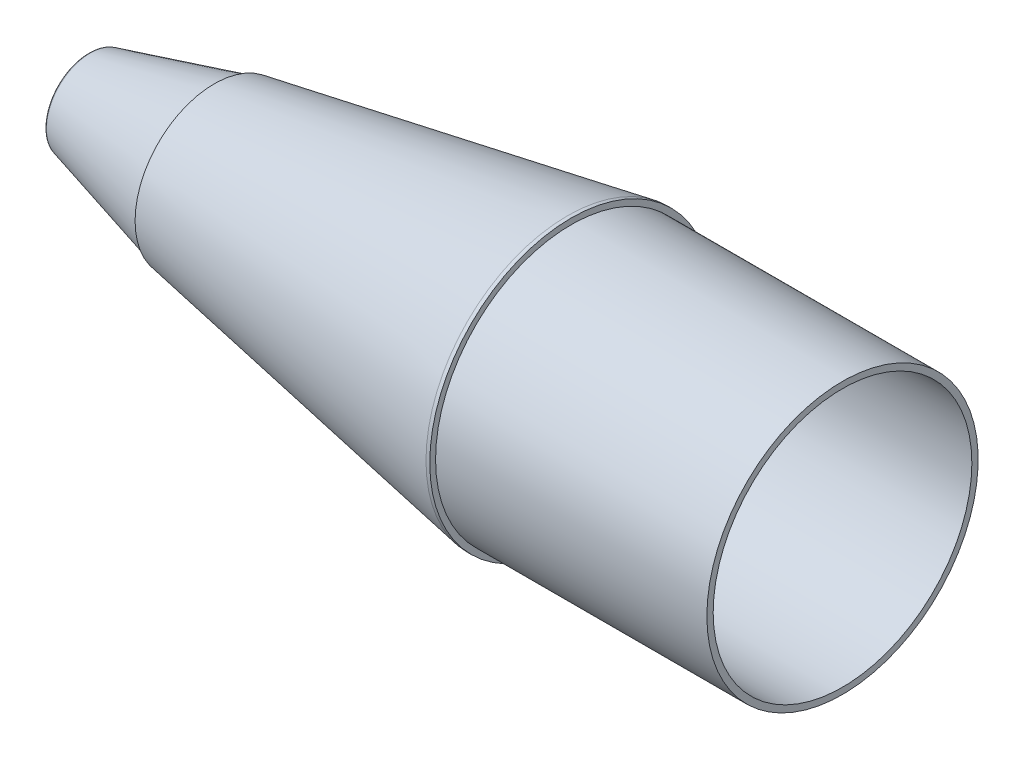
from build123d import *

# Parameters (mm, degrees)
FILLET1_R                    = 1.5494
F_0_257_DIAMETER_HOLE1_D     = 6.5278
F_0_257_DIAMETER_HOLE1_DEPTH = 13.913851026
F_0_257_DIAMETER_HOLE1_TIP   = 1.961148974
FILLET2_R                    = 0.508
SKETCH4_R                    = 7.366
CUT_EXTRUDE1_DEPTH           = 24.13
CUT_EXTRUDE1_TAPER           = -15
FILLET3_R                    = 0.254
CUT_EXTRUDE2_REACH           = 153.771
SKETCH5_R                    = 8.0264


with BuildPart() as part:
    # Sketch1 → Revolve1 (revolve)
    with BuildSketch(Plane.XY):
        Polygon((25.310022167, 15.9385), (96.398972647, 28.4734), (97.160972647, 28.4734), (97.160972647, 27.305), (151.770972647, 27.305), (151.770972647, 26.035), (91.346485275, 26.035), (27.94, 14.854725894), (27.94, 0), (0, 0), (0, 8.7376), (25.310022167, 15.5194), align=None)
    revolve(axis=Axis((0, 0, 0), (1, 0, 0)))

    # Fillet1
    fillet1_edges = [part.edges().sort_by_distance(p)[0] for p in [
        (27.94, -14.854725894, 0),
    ]]
    fillet(fillet1_edges, radius=FILLET1_R)

    # F (0.257) Diameter Hole1
    with Locations(Plane(origin=(27.94, 0, 0), x_dir=(0, 0, -1), z_dir=(1, 0, 0))):
        with Locations((0, 0)):
            Hole(F_0_257_DIAMETER_HOLE1_D / 2, depth=F_0_257_DIAMETER_HOLE1_DEPTH)
            with Locations((0, 0, -(F_0_257_DIAMETER_HOLE1_DEPTH + F_0_257_DIAMETER_HOLE1_TIP / 2))):  # 118° drill point
                Cone(0, F_0_257_DIAMETER_HOLE1_D / 2, F_0_257_DIAMETER_HOLE1_TIP, mode=Mode.SUBTRACT)

    # Fillet2
    fillet2_edges = [part.edges().sort_by_distance(p)[0] for p in [
        (0, -8.7376, 0),
    ]]
    fillet(fillet2_edges, radius=FILLET2_R)

    # Sketch4 → Cut-Extrude1 (cut)
    with BuildSketch(Plane.ZY):
        Circle(SKETCH4_R)
    extrude(amount=-CUT_EXTRUDE1_DEPTH, taper=CUT_EXTRUDE1_TAPER, mode=Mode.SUBTRACT)

    # Fillet3
    fillet3_edges = [part.edges().sort_by_distance(p)[0] for p in [
        (24.13, 0, -13.831614013),
    ]]
    fillet(fillet3_edges, radius=FILLET3_R)

    # Sketch5 → Cut-Extrude2 (cut, up to next)
    with BuildSketch(Plane(origin=(0, 0, 0), x_dir=(0, 0, -1), z_dir=(1, 0, 0)), mode=Mode.PRIVATE) as cut_extrude2_sk1:
        Circle(SKETCH5_R)
    cut_extrude2_tool1 = extrude(cut_extrude2_sk1.sketch, amount=CUT_EXTRUDE2_REACH, mode=Mode.PRIVATE) & part.part
    add(cut_extrude2_tool1.solids().sort_by_distance((0, 0, 0))[0], mode=Mode.SUBTRACT)


solid = part.part
